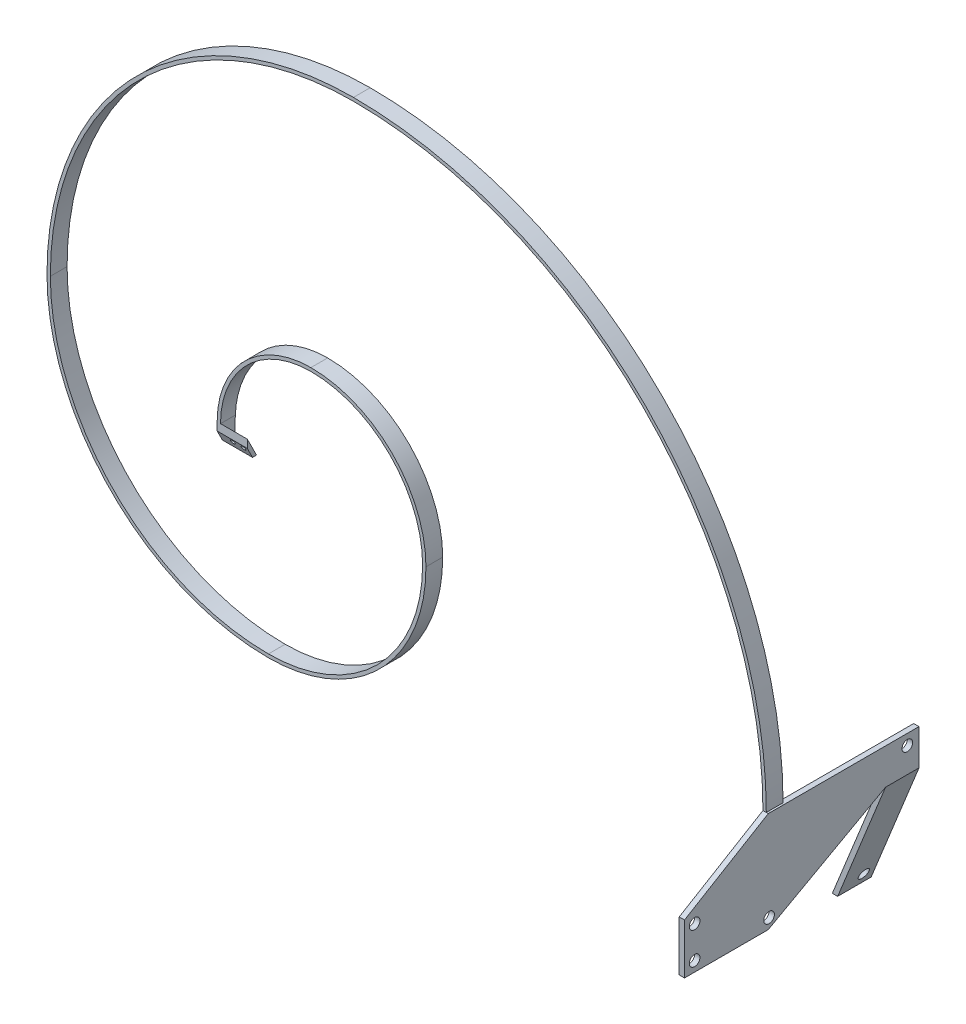
from build123d import *

# Parameters (mm, degrees)
EXTRUDE2_DEPTH     = 5
SKETCH3_W          = 1
SKETCH3_H          = 5
EXTRUDE3_DEPTH     = 10
CUT_EXTRUDE2_DEPTH = 5
EXTRUDE5_DEPTH     = 8
SKETCH8_W          = 1.5875
SKETCH8_H          = 5
EXTRUDE6_DEPTH     = 30
SKETCH9_W          = 1.5875
SKETCH9_H          = 30
EXTRUDE7_DEPTH     = 30
SKETCH10_W         = 1.5875
SKETCH10_H         = 30
EXTRUDE8_DEPTH     = 25
CUT_EXTRUDE3_DEPTH = 5
CUT_EXTRUDE4_DEPTH = 5
CUT_EXTRUDE6_DEPTH = 15
SKETCH15_R         = 0.7
CUT_EXTRUDE7_DEPTH = 10
EXTRUDE9_DEPTH     = 10
SKETCH18_R         = 1.5875
CUT_EXTRUDE8_DEPTH = 3
SKETCH19_R         = 1.5875
CUT_EXTRUDE9_DEPTH = 3


with BuildPart() as part:
    # Sketch2 → Extrude2 (new body)
    with BuildSketch(Plane.XY):
        with BuildLine():
            Line((-27.9875, 0), (-26.9875, 0))
            ThreePointArc((-26.9875, 0), (-19.083044257, 19.083044257), (0, 26.9875))
            ThreePointArc((0, 26.9875), (23.573172318, 17.223172318), (33.3375, -6.35))
            ThreePointArc((33.3375, -6.35), (19.853428439, -38.903428439), (-12.7, -52.3875))
            ThreePointArc((-12.7, -52.3875), (-58.72381262, -33.32381262), (-77.7875, 12.7))
            ThreePointArc((-77.7875, 12.7), (-51.284324863, 76.684324863), (12.7, 103.1875))
            ThreePointArc((12.7, 103.1875), (99.134965165, 67.384965165), (134.9375, -19.05))
            Line((134.9375, -19.05), (135.9375, -19.05))
            ThreePointArc((135.9375, -19.05), (99.842071946, 68.092071946), (12.7, 104.1875))
            ThreePointArc((12.7, 104.1875), (-51.991431644, 77.391431644), (-78.7875, 12.7))
            ThreePointArc((-78.7875, 12.7), (-59.430919402, -34.030919402), (-12.7, -53.3875))
            ThreePointArc((-12.7, -53.3875), (20.56053522, -39.61053522), (34.3375, -6.35))
            ThreePointArc((34.3375, -6.35), (24.280279099, 17.930279099), (0, 27.9875))
            ThreePointArc((0, 27.9875), (-19.790151038, 19.790151038), (-27.9875, 0))
        make_face()
    extrude(amount=EXTRUDE2_DEPTH)

    # Sketch3 → Extrude3 (add)
    with BuildSketch(Plane.XZ):
        with Locations((-27.4875, 2.5)):
            Rectangle(SKETCH3_W, SKETCH3_H)
    extrude(amount=EXTRUDE3_DEPTH)

    # Sketch6 → Cut-Extrude2 (cut)
    with BuildSketch(Plane(origin=(-26.9875, 0, 0), x_dir=(0, 0, -1), z_dir=(1, 0, 0))):
        Polygon((-5, -2.4), (-1.2, -10), (-5, -10), align=None)
    extrude(amount=-CUT_EXTRUDE2_DEPTH, mode=Mode.SUBTRACT)

    # Sketch7 → Extrude5 (add)
    with BuildSketch(Plane(origin=(-26.9875, 0, 0), x_dir=(0, 0, -1), z_dir=(1, 0, 0))):
        Polygon((-5, 0), (0, -10), (-1.2, -10), (-5, -2.4), align=None)
    extrude(amount=EXTRUDE5_DEPTH)

    # Sketch8 → Extrude6 (add)
    with BuildSketch(Plane.XZ.offset(19.05)):
        with Locations((135.73125, 2.5)):
            Rectangle(SKETCH8_W, SKETCH8_H)
    extrude(amount=EXTRUDE6_DEPTH)

    # Sketch9 → Extrude7 (add)
    with BuildSketch(Plane(origin=(0, 0, 0), x_dir=(-1, 0, 0), z_dir=(0, 0, -1))):
        with Locations((-135.73125, -34.05)):
            Rectangle(SKETCH9_W, SKETCH9_H)
    extrude(amount=EXTRUDE7_DEPTH)

    # Sketch10 → Extrude8 (add)
    with BuildSketch(Plane.XY.offset(5)):
        with Locations((135.73125, -34.05)):
            Rectangle(SKETCH10_W, SKETCH10_H)
    extrude(amount=EXTRUDE8_DEPTH)

    # Sketch11 → Cut-Extrude3 (cut)
    with BuildSketch(Plane.ZY.offset(-134.9375)):
        Polygon((5, -19.05), (30, -34.05), (30, -19.05), align=None)
    extrude(amount=-CUT_EXTRUDE3_DEPTH, mode=Mode.SUBTRACT)

    # Sketch12 → Cut-Extrude4 (cut)
    with BuildSketch(Plane.ZY.offset(-134.9375)):
        Polygon((5, -49.05), (-30, -29.728735128), (-30, -49.05), align=None)
    extrude(amount=-CUT_EXTRUDE4_DEPTH, mode=Mode.SUBTRACT)

    # Sketch14 → Cut-Extrude6 (cut)
    with BuildSketch(Plane.ZY.offset(27.9875)):
        Polygon((0, -5.5), (0, 14), (0.8, -5.5), (4.7625, -5.5), (4.7625, -10), (0, -10), align=None)
    extrude(amount=-CUT_EXTRUDE6_DEPTH, mode=Mode.SUBTRACT)

    # Sketch15 → Cut-Extrude7 (cut)
    with BuildSketch(Plane(origin=(0, -2, 4), x_dir=(-1, 0, 0), z_dir=(0, 0.447213595, -0.894427191))):
        with Locations((23.8125, -1)):
            Circle(SKETCH15_R)
        with Locations((20.6375, -1)):
            Circle(SKETCH15_R)
    extrude(amount=-CUT_EXTRUDE7_DEPTH, mode=Mode.SUBTRACT)

    # Sketch17 → Extrude9 (add)
    with BuildSketch(Plane(origin=(0, 0, -30), x_dir=(-1, 0, 0), z_dir=(0, 0, -1))):
        Polygon((-136.525, -19.05), (-136.525, -29.728735128), (-122.24, -65.09), (-120.65, -65.09), (-134.9375, -29.728735128), (-134.9375, -19.05), align=None)
    extrude(amount=EXTRUDE9_DEPTH)

    # Sketch18 → Cut-Extrude8 (cut)
    with BuildSketch(Plane(origin=(126.326271119, -51.041347224, 0), x_dir=(0, 0, 1), z_dir=(-0.927178193, 0.374620605, 0))):
        with Locations((-36.5125, -11.1125)):
            Circle(SKETCH18_R)
    extrude(amount=-CUT_EXTRUDE8_DEPTH, mode=Mode.SUBTRACT)

    # Sketch19 → Cut-Extrude9 (cut)
    with BuildSketch(Plane(origin=(136.525, 0, 0), x_dir=(0, 0, -1), z_dir=(1, 0, 0))):
        with Locations((-26.9875, -46.0375)):
            Circle(SKETCH19_R)
        with Locations((-26.9875, -36.5125)):
            Circle(SKETCH19_R)
        with Locations((-4.7625, -46.0375)):
            Circle(SKETCH19_R)
        with Locations((36.5125, -22.225)):
            Circle(SKETCH19_R)
    extrude(amount=-CUT_EXTRUDE9_DEPTH, mode=Mode.SUBTRACT)


solid = part.part
